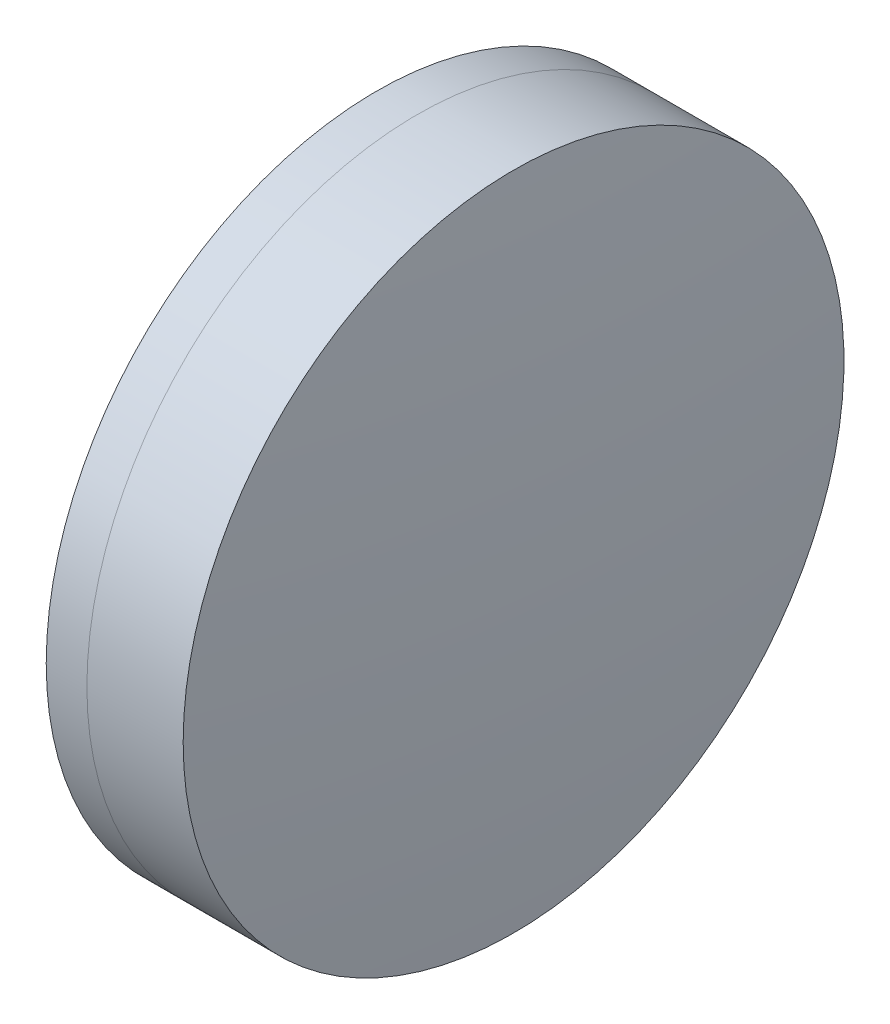
from build123d import *


with BuildPart() as part:
    # 草图1 one side → 旋转1 (revolve)
    with BuildSketch(Plane(origin=(0, 0, 0), x_dir=(1, 0, 0), z_dir=(0, 1, 0)), mode=Mode.PRIVATE) as revolve_1_sk:
        with BuildLine():
            ThreePointArc((58.671244877, 12.5), (57.734839529, 6.281151167), (57.421668974, 0))
            Line((57.421668974, 0), (61.901668974, 0))
            ThreePointArc((61.901668974, 0), (61.476775723, 6.306990294), (60.209774687, 12.5))
            Line((60.209774687, 12.5), (58.671244877, 12.5))
        make_face()
    revolve(revolve_1_sk.sketch.rotate(Axis((-9.702612178, 0, 0), (1, 0, 0)), 180), axis=Axis((-9.702612178, 0, 0), (1, 0, 0)))  # turned: the seam where the file's is


with BuildPart() as body_2:
    # 草图2 one side → 旋转3 (revolve)
    with BuildSketch(Plane(origin=(0, 0, 0), x_dir=(1, 0, 0), z_dir=(0, 1, 0)), mode=Mode.PRIVATE) as revolve_3_sk:
        with BuildLine():
            Line((63.852383987, 12.5), (60.209774687, 12.5))
            ThreePointArc((60.209774687, 12.5), (61.476775723, 6.306990294), (61.901668974, 0))
            Line((61.901668974, 0), (64.401668974, 0))
            ThreePointArc((64.401668974, 0), (64.2642815, 6.25603137), (63.852383987, 12.5))
        make_face()
    revolve(revolve_3_sk.sketch.rotate(Axis((-0.551919993, 0, 0), (1, 0, 0)), 180), axis=Axis((-0.551919993, 0, 0), (1, 0, 0)))  # turned: the seam where the file's is


solid = Compound([part.part, body_2.part])
